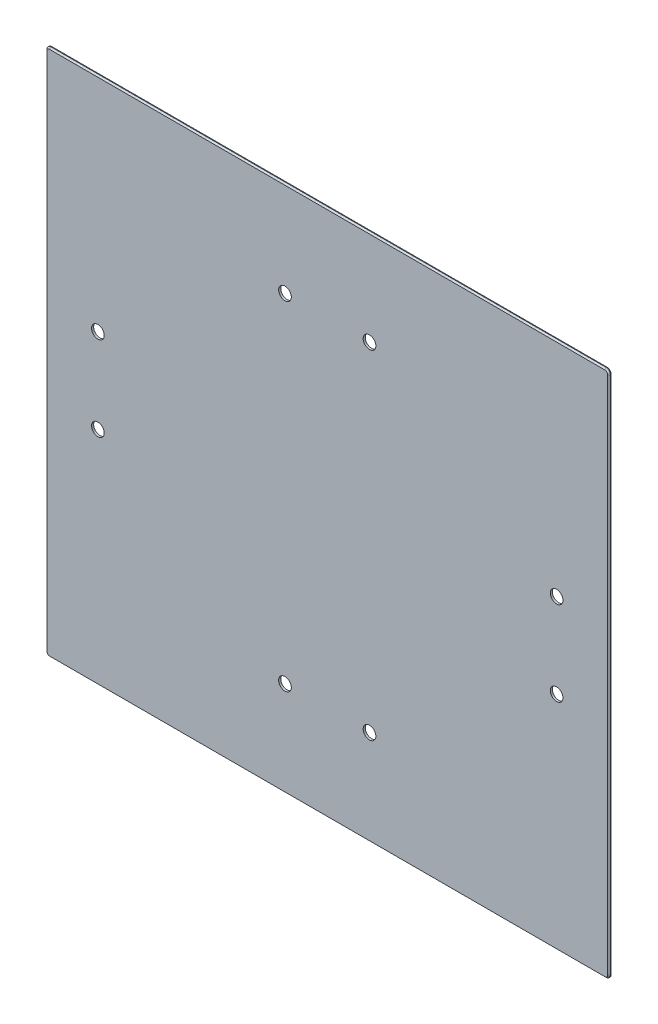
from build123d import *

# Parameters (mm, degrees)
SKETCH1_W           = 400
SKETCH1_H           = 375
BOSS_EXTRUDE1_DEPTH = 1.5
FILLET1_R           = 3
CHAMFER1_SIZE       = 1
SKETCH6_R           = 4.5
CUT_EXTRUDE1_DEPTH  = 10


with BuildPart() as part:
    # Sketch1 → Boss-Extrude1 (new body)
    with BuildSketch(Plane.XY):
        Rectangle(SKETCH1_W, SKETCH1_H)
    extrude(amount=BOSS_EXTRUDE1_DEPTH)

    # Fillet1
    fillet1_edges = [part.edges().sort_by_distance(p)[0] for p in [
        (200, -187.5, 0.75),
        (-200, -187.5, 0.75),
        (-200, 187.5, 0.75),
        (200, 187.5, 0.75),
    ]]
    fillet(fillet1_edges, radius=FILLET1_R)

    # Chamfer1
    chamfer1_edges = [part.edges().sort_by_distance(p)[0] for p in [
        (0, -187.5, 1.5),
        (-200, 0, 1.5),
        (200, 0, 1.5),
        (0, 187.5, 1.5),
        (-199.121320344, 186.621320344, 1.5),
        (199.121320344, 186.621320344, 1.5),
        (199.121320344, -186.621320344, 1.5),
        (-199.121320344, -186.621320344, 1.5),
    ]]
    chamfer(chamfer1_edges, length=CHAMFER1_SIZE)

    # Sketch6 → Cut-Extrude1 (cut)
    with BuildSketch(Plane.XY.offset(1.5)):
        with Locations((-30, 120)):
            Circle(SKETCH6_R)
        with Locations((30, 120)):
            Circle(SKETCH6_R)
        with Locations((162.8, 30)):
            Circle(SKETCH6_R)
        with Locations((162.8, -30)):
            Circle(SKETCH6_R)
        with Locations((30, -120)):
            Circle(SKETCH6_R)
        with Locations((-30, -120)):
            Circle(SKETCH6_R)
        with Locations((-162.8, 30)):
            Circle(SKETCH6_R)
        with Locations((-162.8, -30)):
            Circle(SKETCH6_R)
    extrude(amount=-CUT_EXTRUDE1_DEPTH, mode=Mode.SUBTRACT)


solid = part.part
